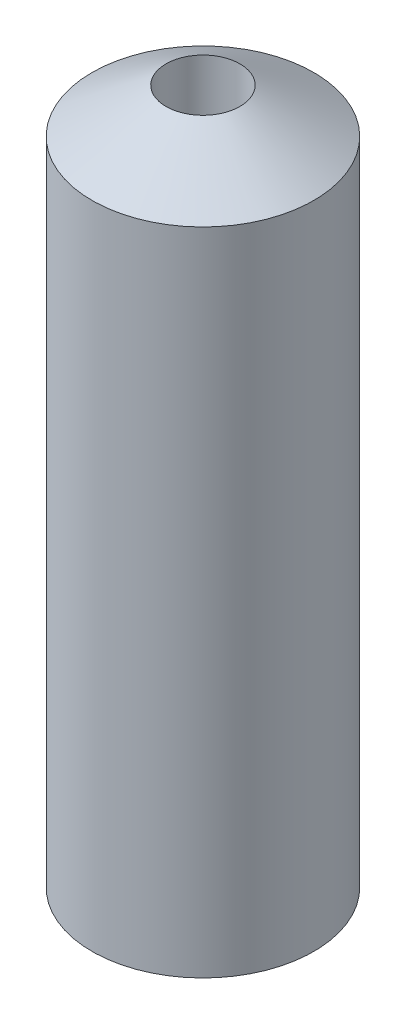
from build123d import *


with BuildPart() as part:
    # Sketch1 → Revolve1 (revolve)
    with BuildSketch(Plane.XY):
        Polygon((0.5, 10), (0.5, 0), (1.5, 0.600860619), (1.5, 9.399139381), align=None)
    revolve(axis=Axis((0, 13.298747267, 0), (0, -1, 0)))


solid = part.part
